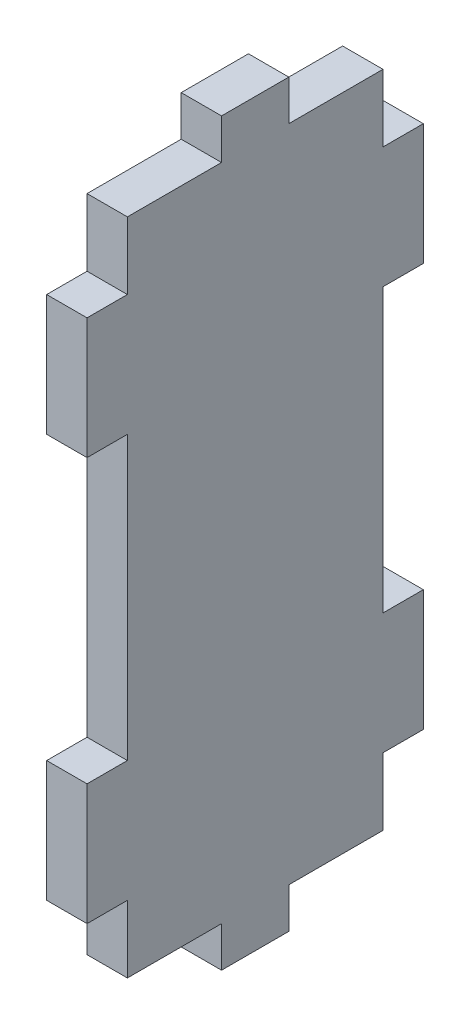
from build123d import *

# Parameters (mm, degrees)
SKETCH_2_W          = 25
SKETCH_2_H          = 55
EXTRUDE_1_DEPTH     = 3
SKETCH_3_W          = 3
SKETCH_3_H          = 8
SKETCH_3_H_2        = 21
CUT_EXTRUDE_1_DEPTH = 4
SKETCH_4_W          = 7
SKETCH_4_H          = 3
CUT_EXTRUDE_2_DEPTH = 4


with BuildPart() as part:
    # 스케치2 → 보스-돌출1 (new body)
    with BuildSketch(Plane(origin=(0, 0, 0), x_dir=(0, 0, -1), z_dir=(1, 0, 0))):
        with Locations((12.5, 27.5)):
            Rectangle(SKETCH_2_W, SKETCH_2_H)
    extrude(amount=EXTRUDE_1_DEPTH)

    # 스케치3 → 컷-돌출1 (cut, through all)
    with BuildSketch(Plane(origin=(3, 0, 0), x_dir=(0, 0, -1), z_dir=(1, 0, 0))):
        with Locations((1.5, 51)):
            Rectangle(SKETCH_3_W, SKETCH_3_H)
        with Locations((23.5, 51)):
            Rectangle(SKETCH_3_W, SKETCH_3_H)
        with Locations((23.5, 27.5)):
            Rectangle(SKETCH_3_W, SKETCH_3_H_2)
        with Locations((1.5, 27.5)):
            Rectangle(SKETCH_3_W, SKETCH_3_H_2)
        with Locations((1.5, 4)):
            Rectangle(SKETCH_3_W, SKETCH_3_H)
        with Locations((23.5, 4)):
            Rectangle(SKETCH_3_W, SKETCH_3_H)
    extrude(amount=-CUT_EXTRUDE_1_DEPTH, mode=Mode.SUBTRACT)

    # 스케치4 → 컷-돌출2 (cut, through all)
    with BuildSketch(Plane(origin=(3, 0, 0), x_dir=(0, 0, -1), z_dir=(1, 0, 0))):
        with Locations((6.5, 53.5)):
            Rectangle(SKETCH_4_W, SKETCH_4_H)
        with Locations((18.5, 53.5)):
            Rectangle(SKETCH_4_W, SKETCH_4_H)
        with Locations((18.5, 1.5)):
            Rectangle(SKETCH_4_W, SKETCH_4_H)
        with Locations((6.5, 1.5)):
            Rectangle(SKETCH_4_W, SKETCH_4_H)
    extrude(amount=-CUT_EXTRUDE_2_DEPTH, mode=Mode.SUBTRACT)


solid = part.part
